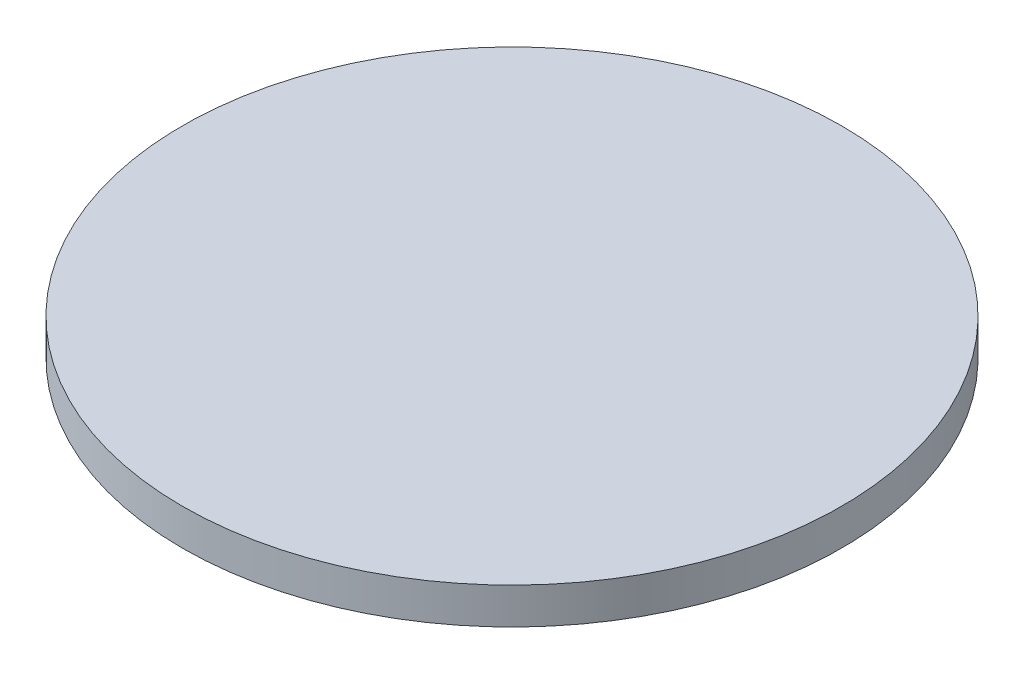
from build123d import *

# Parameters (mm, degrees)
SKETCH1_R           = 27.225
BOSS_EXTRUDE1_DEPTH = 3


with BuildPart() as part:
    # Sketch1 → Boss-Extrude1 (new body)
    with BuildSketch(Plane(origin=(0, 0, 0), x_dir=(1, 0, 0), z_dir=(0, 1, 0))):
        Circle(SKETCH1_R)
    extrude(amount=BOSS_EXTRUDE1_DEPTH)


solid = part.part
